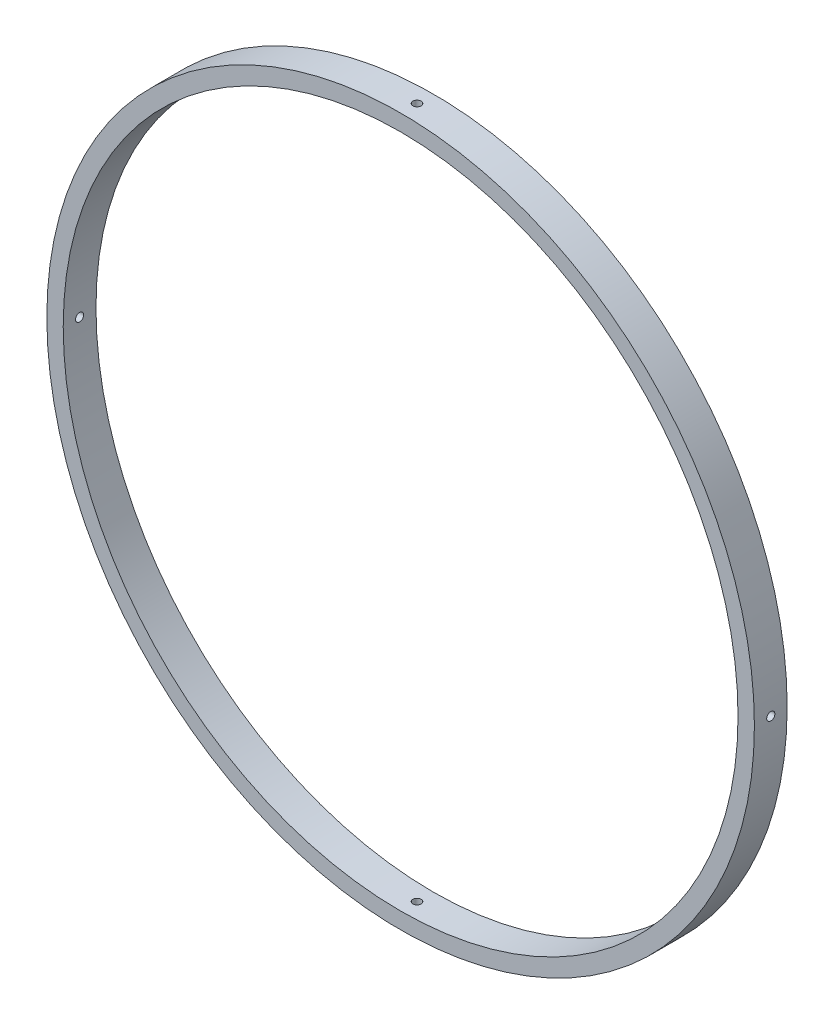
from build123d import *

# Parameters (mm, degrees)
SKETCH3_R           = 68.58
SKETCH3_R_2         = 65.405
BOSS_EXTRUDE1_DEPTH = 3.175
SKETCH4_R           = 0.79375
CUT_EXTRUDE1_DEPTH  = 98.038721266
CIRPATTERN1_COUNT   = 4


with BuildPart() as part:
    # Sketch3 → Boss-Extrude1 (new, symmetric)
    with BuildSketch(Plane.XY):
        Circle(SKETCH3_R)
        Circle(SKETCH3_R_2, mode=Mode.SUBTRACT)
    extrude(amount=BOSS_EXTRUDE1_DEPTH, both=True)

    # Sketch4 → Cut-Extrude1 (cut, through all)
    with BuildSketch(Plane(origin=(0, 0, 0), x_dir=(1, 0, 0), z_dir=(0, 1, 0))):
        with Locations(Location((0, 0, 0), (0, 0, 270))):
            Circle(SKETCH4_R)
    cut_extrude1 = extrude(amount=-CUT_EXTRUDE1_DEPTH, mode=Mode.SUBTRACT)

    # CirPattern1: Cut-Extrude1 ×4 about axis
    cirpattern1_axis = Axis((0, 0, 3.175), (0, 0, -1))
    for i in range(1, CIRPATTERN1_COUNT):
        add(cut_extrude1.rotate(cirpattern1_axis, i * 360 / CIRPATTERN1_COUNT), mode=Mode.SUBTRACT)


solid = part.part
